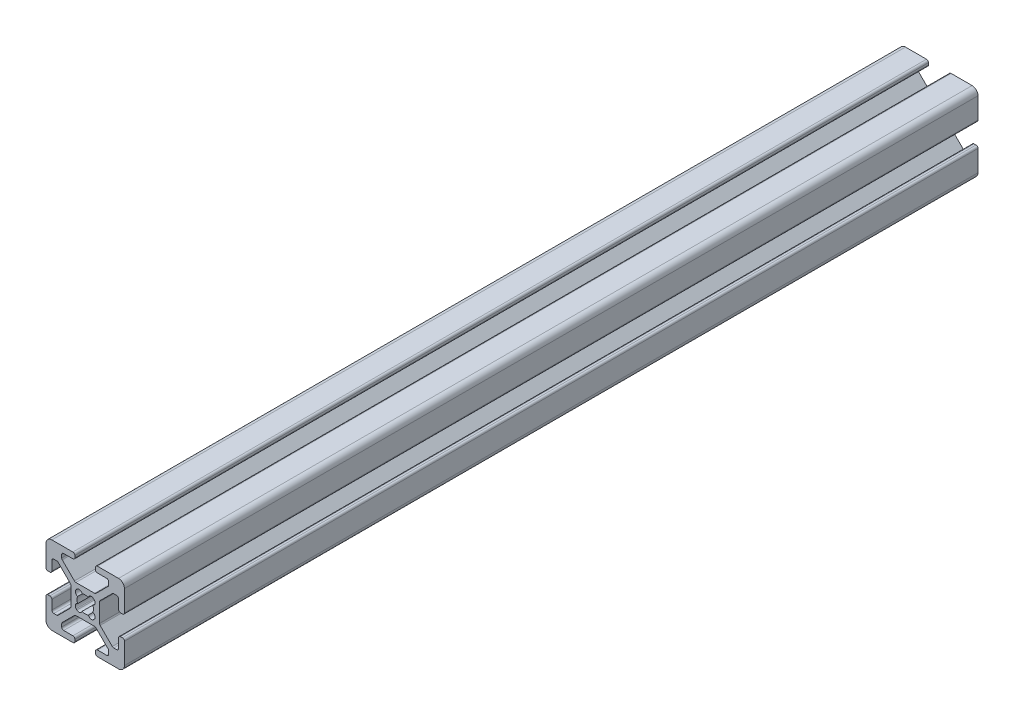
from build123d import *

# Parameters (mm, degrees)
BOSS_EXTRUDE1_DEPTH = 217.678


with BuildPart() as part:
    # Sketch1 → Boss-Extrude1 (new body)
    with BuildSketch(Plane(origin=(0, 0, -4000), x_dir=(-1, 0, 0), z_dir=(0, 0, -1))):
        with BuildLine():
            Line((10, -8.5), (10, -3.138))
            ThreePointArc((10, -3.138), (9.851210245, -2.778789755), (9.492, -2.63))
            Line((9.492, -2.63), (9.008, -2.63))
            ThreePointArc((9.008, -2.63), (8.648789755, -2.778789755), (8.5, -3.138))
            Line((8.5, -3.138), (8.5, -5.487))
            ThreePointArc((8.5, -5.487), (8.351210245, -5.846210245), (7.992, -5.995))
            Line((7.992, -5.995), (7.26592049, -5.995))
            ThreePointArc((7.26592049, -5.995), (7.071517306, -5.956330803), (6.906710245, -5.846210245))
            Line((6.906710245, -5.846210245), (3.803789755, -2.743289755))
            ThreePointArc((3.803789755, -2.743289755), (3.693669197, -2.578482694), (3.655, -2.38407951))
            Line((3.655, -2.38407951), (3.655, 2.383759167))
            ThreePointArc((3.655, 2.383759167), (3.693669197, 2.57816235), (3.803789755, 2.742969412))
            Line((3.803789755, 2.742969412), (6.907030588, 5.846210245))
            ThreePointArc((6.907030588, 5.846210245), (7.07183765, 5.956330803), (7.266240833, 5.995))
            Line((7.266240833, 5.995), (7.992, 5.995))
            ThreePointArc((7.992, 5.995), (8.351210245, 5.846210245), (8.5, 5.487))
            Line((8.5, 5.487), (8.5, 3.138))
            ThreePointArc((8.5, 3.138), (8.648789755, 2.778789755), (9.008, 2.63))
            Line((9.008, 2.63), (9.492, 2.63))
            ThreePointArc((9.492, 2.63), (9.851210245, 2.778789755), (10, 3.138))
            Line((10, 3.138), (10, 8.5))
            ThreePointArc((10, 8.5), (9.560660172, 9.560660172), (8.5, 10))
            Line((8.5, 10), (3.138, 10))
            ThreePointArc((3.138, 10), (2.778789755, 9.851210245), (2.63, 9.492))
            Line((2.63, 9.492), (2.63, 9.008))
            ThreePointArc((2.63, 9.008), (2.778789755, 8.648789755), (3.138, 8.5))
            Line((3.138, 8.5), (5.487, 8.5))
            ThreePointArc((5.487, 8.5), (5.846210245, 8.351210245), (5.995, 7.992))
            Line((5.995, 7.992), (5.995, 7.26592049))
            ThreePointArc((5.995, 7.26592049), (5.956330803, 7.071517306), (5.846210245, 6.906710245))
            Line((5.846210245, 6.906710245), (2.743289755, 3.803789755))
            ThreePointArc((2.743289755, 3.803789755), (2.578482694, 3.693669197), (2.38407951, 3.655))
            Line((2.38407951, 3.655), (-2.383759167, 3.655))
            ThreePointArc((-2.383759167, 3.655), (-2.57816235, 3.693669197), (-2.742969412, 3.803789755))
            Line((-2.742969412, 3.803789755), (-5.846210245, 6.907030588))
            ThreePointArc((-5.846210245, 6.907030588), (-5.956330803, 7.07183765), (-5.995, 7.266240833))
            Line((-5.995, 7.266240833), (-5.995, 7.992))
            ThreePointArc((-5.995, 7.992), (-5.846210245, 8.351210245), (-5.487, 8.5))
            Line((-5.487, 8.5), (-3.138, 8.5))
            ThreePointArc((-3.138, 8.5), (-2.778789755, 8.648789755), (-2.63, 9.008))
            Line((-2.63, 9.008), (-2.63, 9.492))
            ThreePointArc((-2.63, 9.492), (-2.778789755, 9.851210245), (-3.138, 10))
            Line((-3.138, 10), (-8.5, 10))
            ThreePointArc((-8.5, 10), (-9.560660172, 9.560660172), (-10, 8.5))
            Line((-10, 8.5), (-10, 3.138))
            ThreePointArc((-10, 3.138), (-9.851210245, 2.778789755), (-9.492, 2.63))
            Line((-9.492, 2.63), (-9.008, 2.63))
            ThreePointArc((-9.008, 2.63), (-8.648789755, 2.778789755), (-8.5, 3.138))
            Line((-8.5, 3.138), (-8.5, 5.487))
            ThreePointArc((-8.5, 5.487), (-8.351210245, 5.846210245), (-7.992, 5.995))
            Line((-7.992, 5.995), (-7.26592049, 5.995))
            ThreePointArc((-7.26592049, 5.995), (-7.071517306, 5.956330803), (-6.906710245, 5.846210245))
            Line((-6.906710245, 5.846210245), (-3.803789755, 2.743289755))
            ThreePointArc((-3.803789755, 2.743289755), (-3.693669197, 2.578482694), (-3.655, 2.38407951))
            Line((-3.655, 2.38407951), (-3.655, -2.383759167))
            ThreePointArc((-3.655, -2.383759167), (-3.693669197, -2.57816235), (-3.803789755, -2.742969412))
            Line((-3.803789755, -2.742969412), (-6.907030588, -5.846210245))
            ThreePointArc((-6.907030588, -5.846210245), (-7.07183765, -5.956330803), (-7.266240833, -5.995))
            Line((-7.266240833, -5.995), (-7.992, -5.995))
            ThreePointArc((-7.992, -5.995), (-8.351210245, -5.846210245), (-8.5, -5.487))
            Line((-8.5, -5.487), (-8.5, -3.138))
            ThreePointArc((-8.5, -3.138), (-8.648789755, -2.778789755), (-9.008, -2.63))
            Line((-9.008, -2.63), (-9.492, -2.63))
            ThreePointArc((-9.492, -2.63), (-9.851210245, -2.778789755), (-10, -3.138))
            Line((-10, -3.138), (-10, -8.5))
            ThreePointArc((-10, -8.5), (-9.560660172, -9.560660172), (-8.5, -10))
            Line((-8.5, -10), (-3.138, -10))
            ThreePointArc((-3.138, -10), (-2.778789755, -9.851210245), (-2.63, -9.492))
            Line((-2.63, -9.492), (-2.63, -9.008))
            ThreePointArc((-2.63, -9.008), (-2.778789755, -8.648789755), (-3.138, -8.5))
            Line((-3.138, -8.5), (-5.487, -8.5))
            ThreePointArc((-5.487, -8.5), (-5.846210245, -8.351210245), (-5.995, -7.992))
            Line((-5.995, -7.992), (-5.995, -7.26592049))
            ThreePointArc((-5.995, -7.26592049), (-5.956330803, -7.071517306), (-5.846210245, -6.906710245))
            Line((-5.846210245, -6.906710245), (-2.743289755, -3.803789755))
            ThreePointArc((-2.743289755, -3.803789755), (-2.578482694, -3.693669197), (-2.38407951, -3.655))
            Line((-2.38407951, -3.655), (2.383759167, -3.655))
            ThreePointArc((2.383759167, -3.655), (2.57816235, -3.693669197), (2.742969412, -3.803789755))
            Line((2.742969412, -3.803789755), (5.846210245, -6.907030588))
            ThreePointArc((5.846210245, -6.907030588), (5.956330803, -7.07183765), (5.995, -7.266240833))
            Line((5.995, -7.266240833), (5.995, -7.992))
            ThreePointArc((5.995, -7.992), (5.846210245, -8.351210245), (5.487, -8.5))
            Line((5.487, -8.5), (3.138, -8.5))
            ThreePointArc((3.138, -8.5), (2.778789755, -8.648789755), (2.63, -9.008))
            Line((2.63, -9.008), (2.63, -9.492))
            ThreePointArc((2.63, -9.492), (2.778789755, -9.851210245), (3.138, -10))
            Line((3.138, -10), (8.5, -10))
            ThreePointArc((8.5, -10), (9.560660172, -9.560660172), (10, -8.5))
        make_face()
        with BuildLine():
            Line((2.304493037, -2.124493037), (2.124493037, -2.304493037))
            ThreePointArc((2.124493037, -2.304493037), (1.35638567, -2.506016078), (0.803729988, -1.935777391))
            ThreePointArc((0.803729988, -1.935777391), (0, -2.096), (-0.803729988, -1.935777391))
            ThreePointArc((-0.803729988, -1.935777391), (-1.35638567, -2.506016078), (-2.124493037, -2.304493037))
            Line((-2.124493037, -2.304493037), (-2.304493037, -2.124493037))
            ThreePointArc((-2.304493037, -2.124493037), (-2.506016078, -1.35638567), (-1.935777391, -0.803729988))
            ThreePointArc((-1.935777391, -0.803729988), (-2.096, 0), (-1.935777391, 0.803729988))
            ThreePointArc((-1.935777391, 0.803729988), (-2.506016078, 1.35638567), (-2.304493037, 2.124493037))
            Line((-2.304493037, 2.124493037), (-2.124493037, 2.304493037))
            ThreePointArc((-2.124493037, 2.304493037), (-1.35638567, 2.506016078), (-0.803729988, 1.935777391))
            ThreePointArc((-0.803729988, 1.935777391), (0, 2.096), (0.803729988, 1.935777391))
            ThreePointArc((0.803729988, 1.935777391), (1.35638567, 2.506016078), (2.124493037, 2.304493037))
            Line((2.124493037, 2.304493037), (2.304493037, 2.124493037))
            ThreePointArc((2.304493037, 2.124493037), (2.506016078, 1.35638567), (1.935777391, 0.803729988))
            ThreePointArc((1.935777391, 0.803729988), (2.096, 0), (1.935777391, -0.803729988))
            ThreePointArc((1.935777391, -0.803729988), (2.506016078, -1.35638567), (2.304493037, -2.124493037))
        make_face(mode=Mode.SUBTRACT)
    extrude(amount=-BOSS_EXTRUDE1_DEPTH)


solid = part.part
